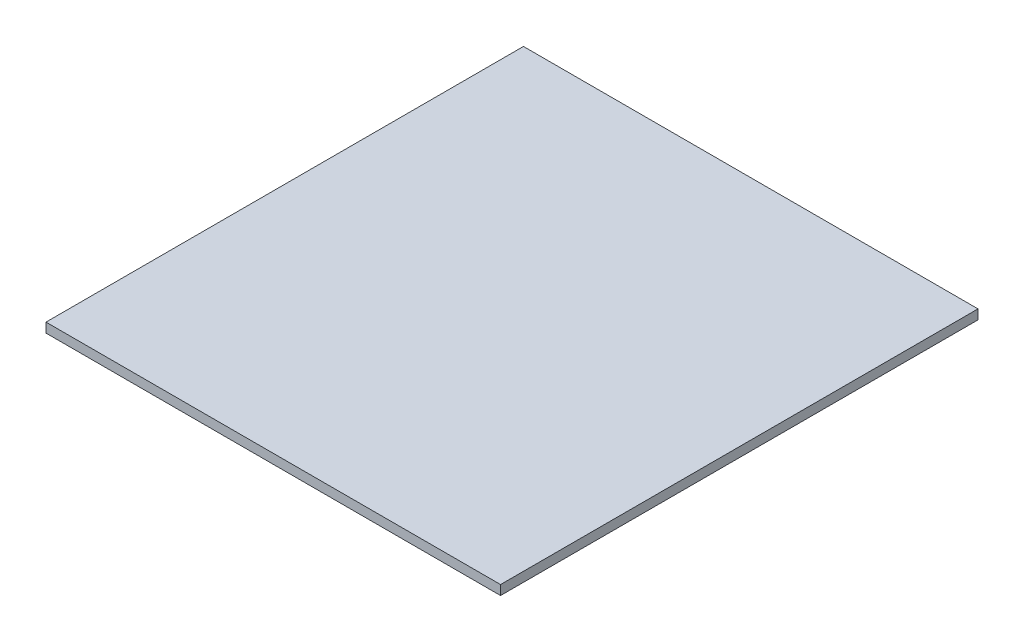
from build123d import *

# Parameters (mm, degrees)
SKETCH_1_W      = 238
SKETCH_1_H      = 250
EXTRUDE_1_DEPTH = 5


with BuildPart() as part:
    # Эскиз1 → Бобышка-Вытянуть1 (new body)
    with BuildSketch(Plane(origin=(0, 0, 0), x_dir=(1, 0, 0), z_dir=(0, 1, 0))):
        with Locations((119, 125)):
            Rectangle(SKETCH_1_W, SKETCH_1_H)
    extrude(amount=EXTRUDE_1_DEPTH)


solid = part.part
